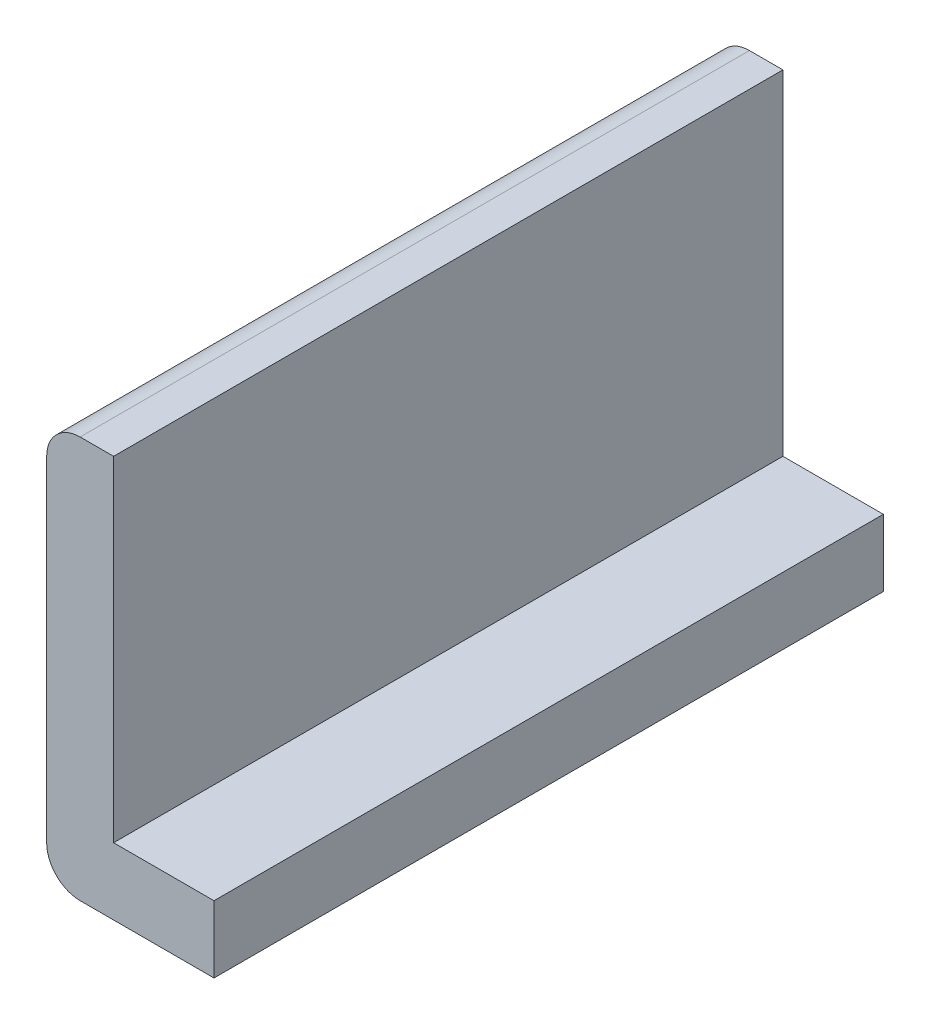
from build123d import *

# Parameters (mm, degrees)
EXTRUSION1_DEPTH = 2


with BuildPart() as part:
    # Esquisse1 → Extrusion1 (new body)
    with BuildSketch(Plane.XY):
        with BuildLine():
            Line((0, 0.1), (0, 1.1))
            ThreePointArc((0, 1.1), (0.029289322, 1.170710678), (0.1, 1.2))
            Line((0.1, 1.2), (0.2, 1.2))
            Line((0.2, 1.2), (0.2, 0.2))
            Line((0.2, 0.2), (0.5, 0.2))
            Line((0.5, 0.2), (0.5, 0))
            Line((0.5, 0), (0.1, 0))
            ThreePointArc((0.1, 0), (0.029289322, 0.029289322), (0, 0.1))
        make_face()
    extrude(amount=EXTRUSION1_DEPTH)


solid = part.part
